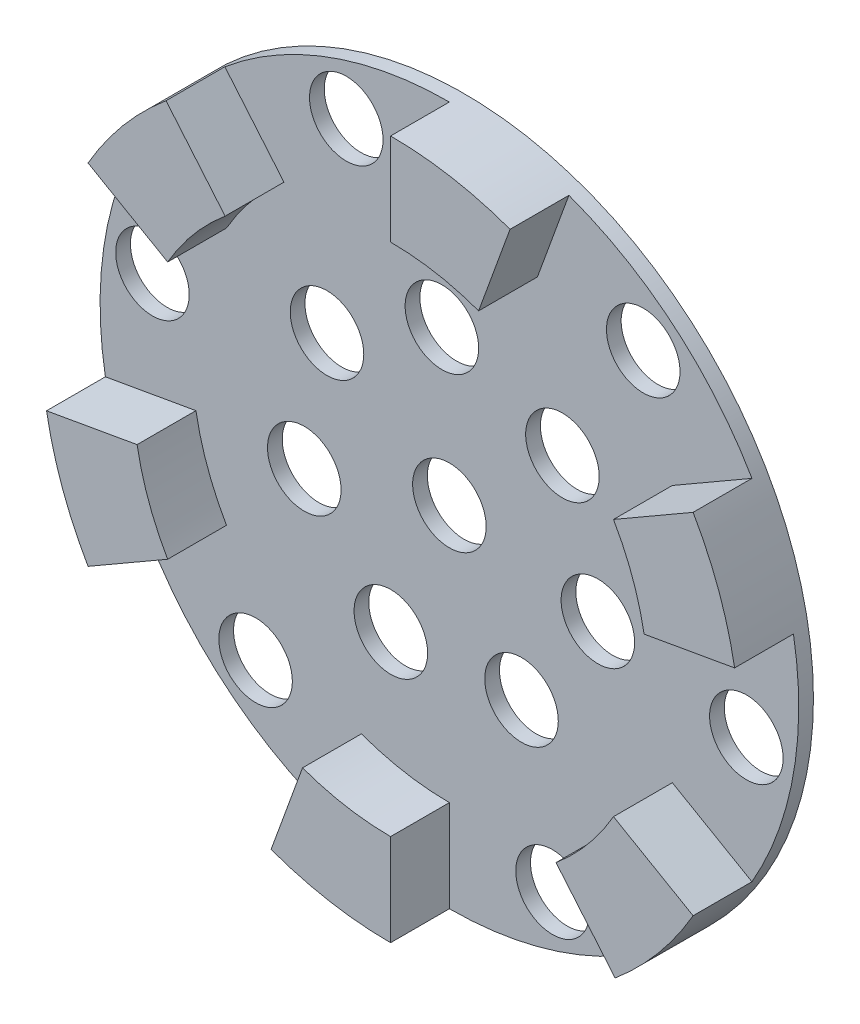
from build123d import *

# Parameters (mm, degrees)
SKETCH1_R           = 5
BOSS_EXTRUDE1_DEPTH = 2
BOSS_EXTRUDE2_DEPTH = 10


with BuildPart() as part:
    # Sketch1 → Boss-Extrude1 (new body)
    with BuildSketch(Plane.XY):
        with BuildLine():
            ThreePointArc((0, 47.5), (-16.245956808, 44.635399487), (-30.53241146, 36.387111048))
            Line((-30.53241146, 36.387111048), (-22.497566339, 26.811555509))
            ThreePointArc((-22.497566339, 26.811555509), (-26.811555509, 22.497566339), (-30.310889132, 17.5))
            Line((-30.310889132, 17.5), (-41.13620668, 23.75))
            ThreePointArc((-41.13620668, 23.75), (-46.778368268, 8.248288439), (-46.778368268, -8.248288439))
            Line((-46.778368268, -8.248288439), (-34.468271355, -6.077686218))
            ThreePointArc((-34.468271355, -6.077686218), (-32.889241728, -11.970705016), (-30.310889132, -17.5))
            Line((-30.310889132, -17.5), (-41.13620668, -23.75))
            ThreePointArc((-41.13620668, -23.75), (-30.53241146, -36.387111048), (-16.245956808, -44.635399487))
            Line((-16.245956808, -44.635399487), (-11.970705016, -32.889241728))
            ThreePointArc((-11.970705016, -32.889241728), (-6.077686218, -34.468271355), (0, -35))
            Line((0, -35), (0, -47.5))
            ThreePointArc((0, -47.5), (16.245956808, -44.635399487), (30.53241146, -36.387111048))
            Line((30.53241146, -36.387111048), (22.497566339, -26.811555509))
            ThreePointArc((22.497566339, -26.811555509), (26.811555509, -22.497566339), (30.310889132, -17.5))
            Line((30.310889132, -17.5), (41.13620668, -23.75))
            ThreePointArc((41.13620668, -23.75), (46.778368268, -8.248288439), (46.778368268, 8.248288439))
            Line((46.778368268, 8.248288439), (34.468271355, 6.077686218))
            ThreePointArc((34.468271355, 6.077686218), (32.889241728, 11.970705016), (30.310889132, 17.5))
            Line((30.310889132, 17.5), (41.13620668, 23.75))
            ThreePointArc((41.13620668, 23.75), (30.53241146, 36.387111048), (16.245956808, 44.635399487))
            Line((16.245956808, 44.635399487), (11.970705016, 32.889241728))
            ThreePointArc((11.970705016, 32.889241728), (6.077686218, 34.468271355), (0, 35))
            Line((0, 35), (0, 47.5))
        make_face()
        with Locations((-14.022825876, 38.527397452)):
            Circle(SKETCH1_R, mode=Mode.SUBTRACT)
        with Locations((15.370514661, 13.564559671)):
            Circle(SKETCH1_R, mode=Mode.SUBTRACT)
        with Locations((-7.962913324, -18.890262343)):
            Circle(SKETCH1_R, mode=Mode.SUBTRACT)
        with Locations((-19.733797062, -5.552229597)):
            Circle(SKETCH1_R, mode=Mode.SUBTRACT)
        with Locations((9.804206562, -18.003542254)):
            Circle(SKETCH1_R, mode=Mode.SUBTRACT)
        with Locations((20.188558937, -3.559787642)):
            Circle(SKETCH1_R, mode=Mode.SUBTRACT)
        with Locations((-16.644729117, 11.966745281)):
            Circle(SKETCH1_R, mode=Mode.SUBTRACT)
        with Locations((-1.021840656, 20.474516885)):
            Circle(SKETCH1_R, mode=Mode.SUBTRACT)
        Circle(SKETCH1_R, mode=Mode.SUBTRACT)
        with Locations((26.354291997, 31.407822168)):
            Circle(SKETCH1_R, mode=Mode.SUBTRACT)
        with Locations((40.377117874, -7.119575284)):
            Circle(SKETCH1_R, mode=Mode.SUBTRACT)
        with Locations((14.022825876, -38.527397452)):
            Circle(SKETCH1_R, mode=Mode.SUBTRACT)
        with Locations((-26.354291997, -31.407822168)):
            Circle(SKETCH1_R, mode=Mode.SUBTRACT)
        with Locations((-40.377117874, 7.119575284)):
            Circle(SKETCH1_R, mode=Mode.SUBTRACT)
    extrude(amount=BOSS_EXTRUDE1_DEPTH)

    # Sketch1_3 → Boss-Extrude2 (add)
    with BuildSketch(Plane.XY):
        with BuildLine():
            Line((0, 47.5), (0, 35))
            ThreePointArc((0, 35), (6.077686218, 34.468271355), (11.970705016, 32.889241728))
            Line((11.970705016, 32.889241728), (16.245956808, 44.635399487))
            ThreePointArc((16.245956808, 44.635399487), (8.248288439, 46.778368268), (0, 47.5))
        make_face()
        with BuildLine():
            ThreePointArc((-30.310889132, 17.5), (-26.811555509, 22.497566339), (-22.497566339, 26.811555509))
            Line((-22.497566339, 26.811555509), (-30.53241146, 36.387111048))
            ThreePointArc((-30.53241146, 36.387111048), (-36.387111048, 30.53241146), (-41.13620668, 23.75))
            Line((-41.13620668, 23.75), (-30.310889132, 17.5))
        make_face()
        with BuildLine():
            Line((41.13620668, 23.75), (30.310889132, 17.5))
            ThreePointArc((30.310889132, 17.5), (32.889241728, 11.970705016), (34.468271355, 6.077686218))
            Line((34.468271355, 6.077686218), (46.778368268, 8.248288439))
            ThreePointArc((46.778368268, 8.248288439), (44.635399487, 16.245956808), (41.13620668, 23.75))
        make_face()
        with BuildLine():
            ThreePointArc((-30.310889132, -17.5), (-32.889241728, -11.970705016), (-34.468271355, -6.077686218))
            Line((-34.468271355, -6.077686218), (-46.778368268, -8.248288439))
            ThreePointArc((-46.778368268, -8.248288439), (-44.635399487, -16.245956808), (-41.13620668, -23.75))
            Line((-41.13620668, -23.75), (-30.310889132, -17.5))
        make_face()
        with BuildLine():
            Line((41.13620668, -23.75), (30.310889132, -17.5))
            ThreePointArc((30.310889132, -17.5), (26.811555509, -22.497566339), (22.497566339, -26.811555509))
            Line((22.497566339, -26.811555509), (30.53241146, -36.387111048))
            ThreePointArc((30.53241146, -36.387111048), (36.387111048, -30.53241146), (41.13620668, -23.75))
        make_face()
        with BuildLine():
            ThreePointArc((0, -35), (-6.077686218, -34.468271355), (-11.970705016, -32.889241728))
            Line((-11.970705016, -32.889241728), (-16.245956808, -44.635399487))
            ThreePointArc((-16.245956808, -44.635399487), (-8.248288439, -46.778368268), (0, -47.5))
            Line((0, -47.5), (0, -35))
        make_face()
    extrude(amount=BOSS_EXTRUDE2_DEPTH)


solid = part.part
